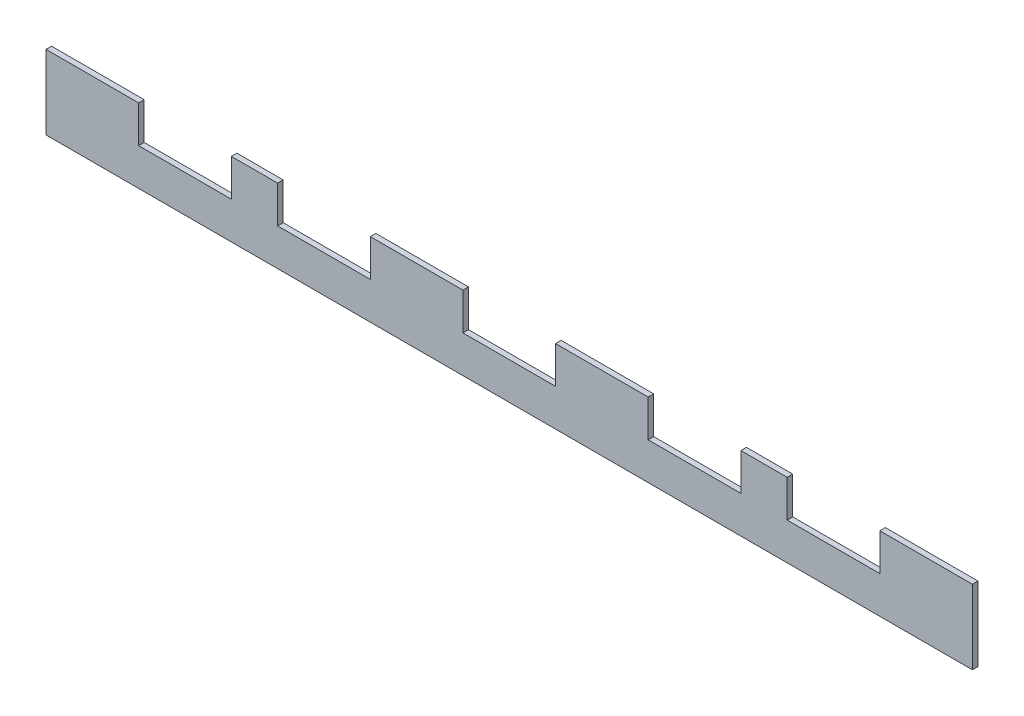
from build123d import *

# Parameters (mm, degrees)
SKETCH1_W           = 500
SKETCH1_H           = 40
BOSS_EXTRUDE1_DEPTH = 3
SKETCH3_W           = 50
SKETCH3_H           = 20
CUT_EXTRUDE2_DEPTH  = 4


with BuildPart() as part:
    # Sketch1 → Boss-Extrude1 (new body)
    with BuildSketch(Plane.XY):
        with Locations((250, 20)):
            Rectangle(SKETCH1_W, SKETCH1_H)
    extrude(amount=BOSS_EXTRUDE1_DEPTH)

    # Sketch3 → Cut-Extrude2 (cut, through all)
    with BuildSketch(Plane.XY.offset(3)):
        with Locations((75, 30)):
            Rectangle(SKETCH3_W, SKETCH3_H)
        with Locations((150, 30)):
            Rectangle(SKETCH3_W, SKETCH3_H)
        with Locations((250, 30)):
            Rectangle(SKETCH3_W, SKETCH3_H)
        with Locations((425, 30)):
            Rectangle(SKETCH3_W, SKETCH3_H)
        with Locations((350, 30)):
            Rectangle(SKETCH3_W, SKETCH3_H)
    extrude(amount=-CUT_EXTRUDE2_DEPTH, mode=Mode.SUBTRACT)


solid = part.part
